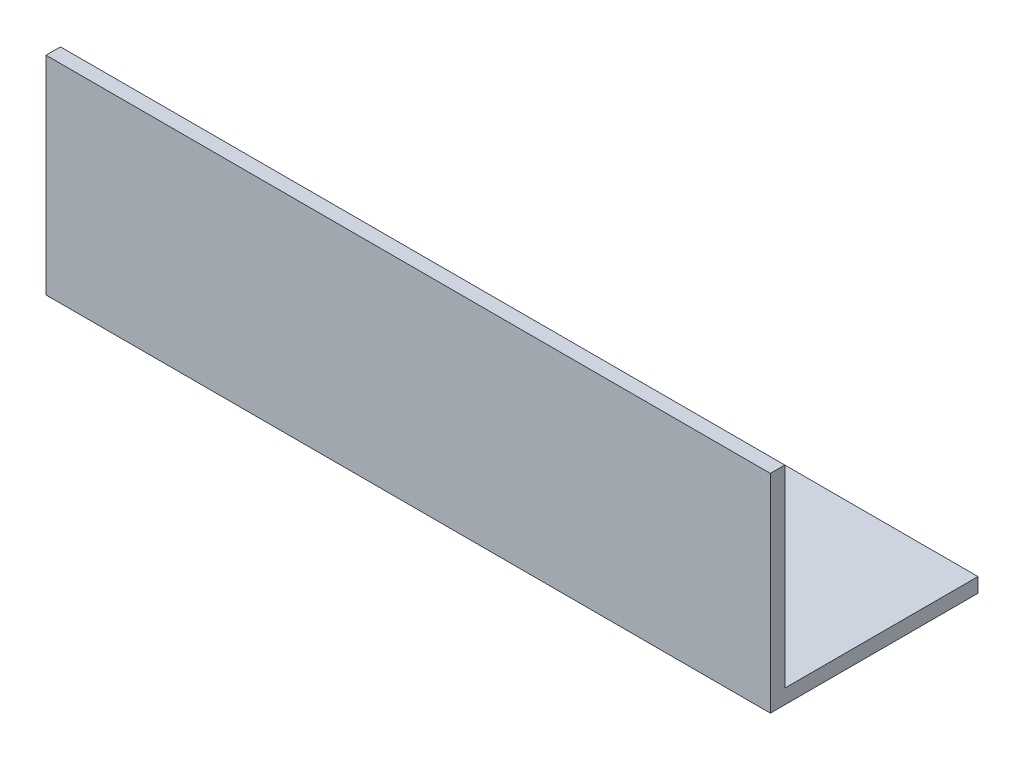
from build123d import *

# Parameters (mm, degrees)
EXTRUDE_1_DEPTH = 150


with BuildPart() as part:
    # Эскиз1 → Вытянуть-Тонкостенный1 (new body)
    with BuildSketch(Plane(origin=(0, 0, 0), x_dir=(0, 0, -1), z_dir=(1, 0, 0))):
        Polygon((0, 40), (0, 0), (40, 0), (40, -3), (-3, -3), (-3, 40), align=None)
    extrude(amount=EXTRUDE_1_DEPTH)


solid = part.part
